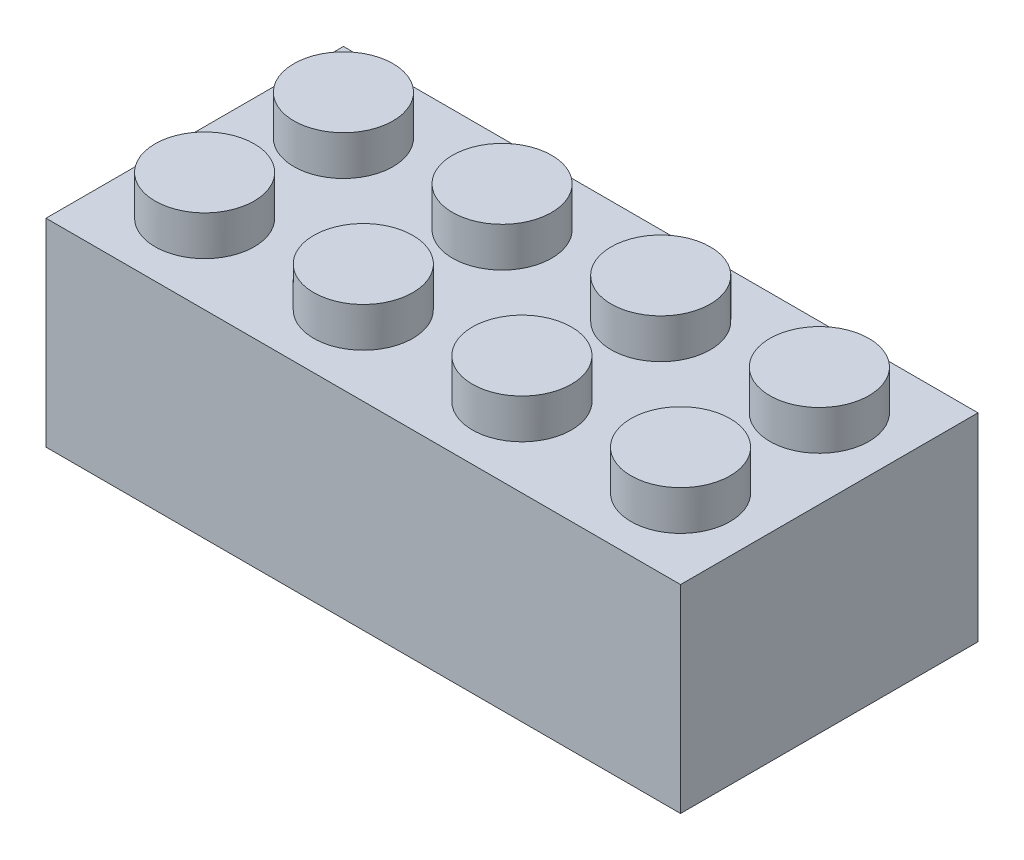
from build123d import *

# Parameters (mm, degrees)
SKETCH1_W           = 32
SKETCH1_H           = 15
BOSS_EXTRUDE1_DEPTH = 10
SKETCH2_R           = 2.5
BOSS_EXTRUDE2_DEPTH = 2
SKETCH3_W           = 30
SKETCH3_H           = 13
CUT_EXTRUDE1_DEPTH  = 9
SKETCH4_R           = 3.5
SKETCH4_R_2         = 3
BOSS_EXTRUDE3_DEPTH = 9
BOSS_EXTRUDE4_DEPTH = 7


with BuildPart() as part:
    # Sketch1 → Boss-Extrude1 (new body)
    with BuildSketch(Plane(origin=(0, 0, 0), x_dir=(1, 0, 0), z_dir=(0, 1, 0))):
        Rectangle(SKETCH1_W, SKETCH1_H)
    extrude(amount=BOSS_EXTRUDE1_DEPTH)

    # Sketch2 → Boss-Extrude2 (add)
    with BuildSketch(Plane(origin=(0, 10, 0), x_dir=(1, 0, 0), z_dir=(0, 1, 0))):
        with Locations((-12, -3.5)):
            Circle(SKETCH2_R)
        with Locations((-4, -3.5)):
            Circle(SKETCH2_R)
        with Locations((4, -3.5)):
            Circle(SKETCH2_R)
        with Locations((12, -3.5)):
            Circle(SKETCH2_R)
        with Locations((12, 3.5)):
            Circle(SKETCH2_R)
        with Locations((4, 3.5)):
            Circle(SKETCH2_R)
        with Locations((-4, 3.5)):
            Circle(SKETCH2_R)
        with Locations((-12, 3.5)):
            Circle(SKETCH2_R)
    extrude(amount=BOSS_EXTRUDE2_DEPTH)

    # Sketch3 → Cut-Extrude1 (cut)
    with BuildSketch(Plane.XZ):
        Rectangle(SKETCH3_W, SKETCH3_H)
    extrude(amount=-CUT_EXTRUDE1_DEPTH, mode=Mode.SUBTRACT)

    # Sketch4 → Boss-Extrude3 (add)
    with BuildSketch(Plane.XZ.offset(-9)):
        Circle(SKETCH4_R)
        Circle(SKETCH4_R_2, mode=Mode.SUBTRACT)
        with Locations((8, 0)):
            Circle(SKETCH4_R)
        with Locations((8, 0)):
            Circle(SKETCH4_R_2, mode=Mode.SUBTRACT)
        with Locations((-8, 0)):
            Circle(SKETCH4_R)
        with Locations((-8, 0)):
            Circle(SKETCH4_R_2, mode=Mode.SUBTRACT)
    extrude(amount=BOSS_EXTRUDE3_DEPTH)

    # Sketch5 → Boss-Extrude4 (add)
    with BuildSketch(Plane.XZ.offset(-9)):
        with BuildLine():
            Line((-0.272235441, -6.5), (0.272235441, -6.5))
            Line((0.272235441, -6.5), (0.272235441, -3.48939649))
            ThreePointArc((0.272235441, -3.48939649), (0, -3.5), (-0.272235441, -3.48939649))
            Line((-0.272235441, -3.48939649), (-0.272235441, -6.5))
        make_face()
        with BuildLine():
            Line((-0.272235441, 6.5), (0.272235441, 6.5))
            Line((0.272235441, 6.5), (0.272235441, 3.48939649))
            ThreePointArc((0.272235441, 3.48939649), (0, 3.5), (-0.272235441, 3.48939649))
            Line((-0.272235441, 3.48939649), (-0.272235441, 6.5))
        make_face()
    extrude(amount=BOSS_EXTRUDE4_DEPTH)


solid = part.part
